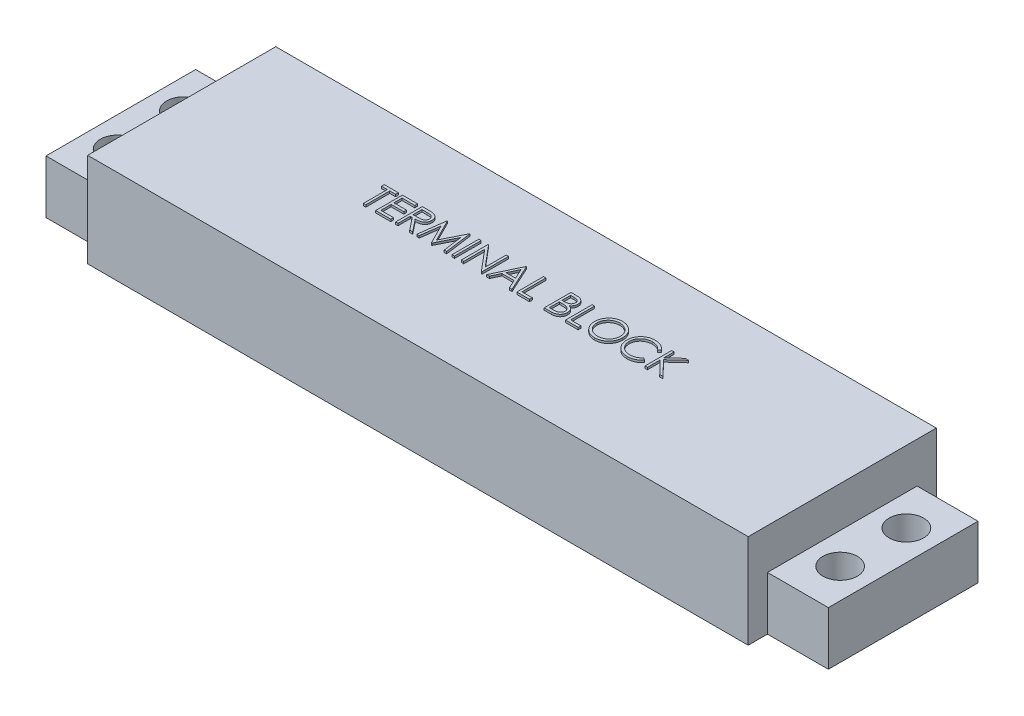
from build123d import *

# Parameters (mm, degrees)
SKETCH1_W           = 78.486
SKETCH1_H           = 22.352
BOSS_EXTRUDE1_DEPTH = 11.176
SKETCH1_4_W         = 7.239
SKETCH1_4_H         = 17.78
BOSS_EXTRUDE2_DEPTH = 6.35
SKETCH2_R           = 2.0499959
CUT_EXTRUDE1_DEPTH  = 49.226567367
SKETCH3_W           = 0.284935897
SKETCH3_H           = 3.175
BOSS_EXTRUDE3_DEPTH = 0.254


with BuildPart() as part:
    # Sketch1 → Boss-Extrude1 (new body)
    with BuildSketch(Plane(origin=(0, 0, 0), x_dir=(1, 0, 0), z_dir=(0, 1, 0))):
        Rectangle(SKETCH1_W, SKETCH1_H)
    extrude(amount=BOSS_EXTRUDE1_DEPTH)

    # Sketch1_4 → Boss-Extrude2 (add)
    with BuildSketch(Plane(origin=(0, 0, 0), x_dir=(1, 0, 0), z_dir=(0, 1, 0))):
        with Locations((-42.8625, 0)):
            Rectangle(SKETCH1_4_W, SKETCH1_4_H)
        with Locations((42.8625, 0)):
            Rectangle(SKETCH1_4_W, SKETCH1_4_H)
    extrude(amount=BOSS_EXTRUDE2_DEPTH)

    # Sketch2 → Cut-Extrude1 (cut, through all)
    with BuildSketch(Plane(origin=(0, 6.35, 0), x_dir=(1, 0, 0), z_dir=(0, 1, 0))):
        with Locations((-42.926, 3.937)):
            Circle(SKETCH2_R)
        with Locations((-42.926, -3.937)):
            Circle(SKETCH2_R)
        with Locations((42.926, -3.937)):
            Circle(SKETCH2_R)
        with Locations((42.926, 3.937)):
            Circle(SKETCH2_R)
    extrude(amount=-CUT_EXTRUDE1_DEPTH, mode=Mode.SUBTRACT)

    # Sketch3 → Boss-Extrude3 (add)
    # profile 1 of 13: a face of its own
    with BuildSketch(Plane(origin=(0, 11.176, 0), x_dir=(1, 0, 0), z_dir=(0, 1, 0))):
        Polygon((-18.35269826, 2.849358974), (-18.35269826, 3.175), (-16.683788004, 3.175), (-16.683788004, 2.849358974), (-17.375775183, 2.849358974), (-17.375775183, 0), (-17.660711081, 0), (-17.660711081, 2.849358974), align=None)
    # profile 2 of 13: a face of its own
    with BuildSketch(Plane(origin=(0, 11.176, 0), x_dir=(1, 0, 0), z_dir=(0, 1, 0))):
        Polygon((-16.195326465, 3.175), (-14.404300824, 3.175), (-14.404300824, 2.849358974), (-15.910390568, 2.849358974), (-15.910390568, 1.872435897), (-14.404300824, 1.872435897), (-14.404300824, 1.546794872), (-15.910390568, 1.546794872), (-15.910390568, 0.325641026), (-14.404300824, 0.325641026), (-14.404300824, 0), (-16.195326465, 0), align=None)
    # profile 3 of 13: a face of its own
    with BuildSketch(Plane(origin=(0, 11.176, 0), x_dir=(1, 0, 0), z_dir=(0, 1, 0))):
        with BuildLine():
            Line((-13.834429029, 3.175), (-13.199047419, 3.175))
            add(Edge.make_bspline(
                [(-13.199047419, 3.175), (-13.156646538, 3.174858861), (-13.07523215, 3.174587859), (-12.958597826, 3.173076774), (-12.852618959, 3.168745752), (-12.757350962, 3.16501868), (-12.672795582, 3.158222418), (-12.59869354, 3.151726689), (-12.535386129, 3.143223439), (-12.497063107, 3.135326377), (-12.479711481, 3.131750801)],
                knots=[0, 0, 0, 0, 1.410062039, 2.707475311, 3.878576406, 4.937260626, 5.877586885, 6.699081471, 7.410979367, 8, 8, 8, 8], degree=3))
            add(Edge.make_bspline(
                [(-12.479711481, 3.131750801), (-12.456482615, 3.126011521), (-12.410520417, 3.114655396), (-12.344344286, 3.090652758), (-12.281284864, 3.062876384), (-12.221604094, 3.030252152), (-12.165600912, 2.992537888), (-12.112697873, 2.950384662), (-12.062654917, 2.904023126), (-12.017495867, 2.852284377), (-11.974915442, 2.798004114), (-11.939002902, 2.739308563), (-11.90804531, 2.677929892), (-11.883397769, 2.613243877), (-11.863551322, 2.545877841), (-11.849557519, 2.475221576), (-11.84116537, 2.401596977), (-11.840310973, 2.351379445), (-11.839877747, 2.325916466)],
                knots=[0, 0, 0, 0, 1.027469482, 2.033020251, 3.019912614, 3.986113645, 4.951240523, 5.91722682, 6.890402269, 7.87763091, 8.8651537, 9.85103654, 10.82876324, 11.815024772, 12.821070561, 13.842952187, 14.906261191, 16, 16, 16, 16], degree=3))
            add(Edge.make_bspline(
                [(-11.839877747, 2.325916466), (-11.841210338, 2.283611764), (-11.843810569, 2.201064333), (-11.868054056, 2.081266248), (-11.907765613, 1.969515941), (-11.962487454, 1.86595412), (-12.032173692, 1.772599463), (-12.115925467, 1.690602407), (-12.2137895, 1.621986201), (-12.304893237, 1.574404013), (-12.38536969, 1.543930446), (-12.451621338, 1.522488892), (-12.523890667, 1.505922681), (-12.601485249, 1.491081704), (-12.684727994, 1.479876953), (-12.773419387, 1.471670399), (-12.867622682, 1.466541369), (-12.932337409, 1.465777551), (-12.965628949, 1.465384615)],
                knots=[0, 0, 0, 0, 1.260483769, 2.459530307, 3.627416485, 4.787058657, 5.939039949, 7.08810263, 8.267026773, 9.491475466, 10.141966685, 10.831826277, 11.566392101, 12.351337768, 13.187381173, 14.07005841, 15.007169909, 16, 16, 16, 16], degree=3))
            Line((-12.965628949, 1.465384615), (-11.799172619, 0))
            Line((-11.799172619, 0), (-12.151526385, 0))
            Line((-12.151526385, 0), (-13.317982715, 1.465384615))
            Line((-13.317982715, 1.465384615), (-13.549493132, 1.465384615))
            Line((-13.549493132, 1.465384615), (-13.549493132, 0))
            Line((-13.549493132, 0), (-13.834429029, 0))
            Line((-13.834429029, 0), (-13.834429029, 3.175))
        make_face()
        with BuildLine():
            Line((-13.549493132, 2.849358974), (-13.549493132, 1.791025641))
            Line((-13.549493132, 1.791025641), (-12.96817302, 1.786573518))
            add(Edge.make_bspline(
                [(-12.96817302, 1.786573518), (-12.94103127, 1.78656151), (-12.888422829, 1.786538236), (-12.81231294, 1.790161162), (-12.741446839, 1.7942826), (-12.676095585, 1.80058665), (-12.616229985, 1.808711086), (-12.56187996, 1.818873793), (-12.512956791, 1.830713879), (-12.455898831, 1.849039639), (-12.392184264, 1.87807367), (-12.322940725, 1.920315229), (-12.263974319, 1.973445788), (-12.214155972, 2.03420028), (-12.174124274, 2.100998877), (-12.145901196, 2.173040869), (-12.12799198, 2.248507533), (-12.125879657, 2.300376245), (-12.124813645, 2.326552484)],
                knots=[0, 0, 0, 0, 1.146690395, 2.22261258, 3.21895312, 4.145990853, 4.996080663, 5.770904154, 6.481378293, 7.121626537, 8.300444488, 9.431385265, 10.535395872, 11.636531494, 12.74115979, 13.810798291, 14.895190096, 16, 16, 16, 16], degree=3))
            add(Edge.make_bspline(
                [(-12.124813645, 2.326552484), (-12.12590414, 2.352085447), (-12.128065105, 2.402682464), (-12.145707916, 2.47675604), (-12.175543283, 2.546666773), (-12.215749885, 2.61213027), (-12.264734833, 2.67155333), (-12.322173134, 2.722396105), (-12.386494275, 2.764350976), (-12.44661172, 2.791161022), (-12.500345612, 2.807598317), (-12.546999661, 2.819165444), (-12.599715073, 2.828458641), (-12.658747811, 2.835904525), (-12.723845861, 2.842304367), (-12.795338381, 2.846614909), (-12.872751031, 2.849167486), (-12.926405747, 2.849293659), (-12.954180632, 2.849358974)],
                knots=[0, 0, 0, 0, 1.101028733, 2.181837193, 3.264309656, 4.369019818, 5.486613113, 6.575447106, 7.666700264, 8.788928104, 9.402425223, 10.0903467, 10.862060571, 11.710948788, 12.657782767, 13.684531032, 14.801375019, 16, 16, 16, 16], degree=3))
            Line((-12.954180632, 2.849358974), (-13.549493132, 2.849358974))
        make_face(mode=Mode.SUBTRACT)
    # profile 4 of 13: a face of its own
    with BuildSketch(Plane(origin=(0, 11.176, 0), x_dir=(1, 0, 0), z_dir=(0, 1, 0))):
        Polygon((-11.310711081, 0), (-10.891575464, 3.175), (-10.850870335, 3.175), (-9.540038004, 0.569871795), (-8.23238576, 3.175), (-8.191044614, 3.175), (-7.769364927, 0), (-8.055572859, 0), (-8.359589286, 2.284575321), (-9.505693052, 0), (-9.569930832, 0), (-10.720486722, 2.289663462), (-11.02386713, 0), align=None)
    # profile 5 of 13: a face of its own
    with BuildSketch(Plane(origin=(0, 11.176, 0), x_dir=(1, 0, 0), z_dir=(0, 1, 0))):
        with Locations((-6.975614927, 1.5875)):
            Rectangle(SKETCH3_W, SKETCH3_H)
    # profile 6 of 13: a face of its own
    with BuildSketch(Plane(origin=(0, 11.176, 0), x_dir=(1, 0, 0), z_dir=(0, 1, 0))):
        Polygon((-6.019044414, 0), (-6.019044414, 3.175), (-5.959258757, 3.175), (-3.861672619, 0.676086739), (-3.861672619, 3.175), (-3.576736722, 3.175), (-3.576736722, 0), (-3.64161052, 0), (-5.734108517, 2.493189103), (-5.734108517, 0), align=None)
    # profile 7 of 13: a face of its own
    with BuildSketch(Plane(origin=(0, 11.176, 0), x_dir=(1, 0, 0), z_dir=(0, 1, 0))):
        Polygon((-1.460070055, 3.175), (0.00531456, 0), (-0.304426025, 0), (-0.773807034, 1.017628205), (-2.213114927, 1.017628205), (-2.695852307, 0), (-3.006864927, 0), (-1.500775183, 3.175), align=None)
        Polygon((-1.483602707, 2.556154848), (-2.058562643, 1.343269231), (-0.923907194, 1.343269231), align=None, mode=Mode.SUBTRACT)
    # profile 8 of 13: a face of its own
    with BuildSketch(Plane(origin=(0, 11.176, 0), x_dir=(1, 0, 0), z_dir=(0, 1, 0))):
        Polygon((0.575186355, 3.175), (0.860122253, 3.175), (0.860122253, 0.325641026), (2.081276099, 0.325641026), (2.081276099, 0), (0.575186355, 0), align=None)
    # profile 9 of 13: a face of its own
    with BuildSketch(Plane(origin=(0, 11.176, 0), x_dir=(1, 0, 0), z_dir=(0, 1, 0))):
        with BuildLine():
            Line((3.831596612, 3.175), (4.451077782, 3.175))
            add(Edge.make_bspline(
                [(4.451077782, 3.175), (4.481402187, 3.174840569), (4.540178431, 3.174531553), (4.625648925, 3.169738998), (4.705703203, 3.163204241), (4.780364482, 3.152835514), (4.849598262, 3.140324401), (4.91361319, 3.125173468), (4.972205704, 3.107006469), (5.042157972, 3.078117342), (5.121914571, 3.035188468), (5.208273113, 2.97175327), (5.282118388, 2.894163107), (5.345787404, 2.806639555), (5.396406991, 2.710359248), (5.433027711, 2.607616984), (5.456212355, 2.499737975), (5.45859672, 2.425675949), (5.45980174, 2.388246194)],
                knots=[0, 0, 0, 0, 1.001505555, 1.941167018, 2.826882275, 3.653841531, 4.429895133, 5.150066043, 5.825578002, 6.45369114, 7.647487171, 8.808567382, 9.977351308, 11.170798116, 12.373658725, 13.556498008, 14.765093433, 16, 16, 16, 16], degree=3))
            add(Edge.make_bspline(
                [(5.45980174, 2.388246194), (5.458810035, 2.353182804), (5.45686124, 2.284279937), (5.438226023, 2.183501709), (5.409051702, 2.087570246), (5.368497655, 1.996835654), (5.315790844, 1.913348019), (5.253326512, 1.836433856), (5.177963984, 1.769349683), (5.121500473, 1.731845764), (5.092819568, 1.712795473)],
                knots=[0, 0, 0, 0, 1.044552857, 2.05264487, 3.044412934, 4.028983338, 5.005914585, 5.980388656, 6.974128949, 8, 8, 8, 8], degree=3))
            add(Edge.make_bspline(
                [(5.092819568, 1.712795473), (5.128887956, 1.698947938), (5.197895717, 1.672454174), (5.292860886, 1.625613431), (5.374680495, 1.574666374), (5.44398362, 1.519029624), (5.503254207, 1.459059489), (5.555009376, 1.393876635), (5.599170336, 1.322630762), (5.637009917, 1.246064698), (5.666536289, 1.164960259), (5.688648716, 1.080078197), (5.701319188, 0.991722887), (5.703122263, 0.931592578), (5.704032509, 0.901236979)],
                knots=[0, 0, 0, 0, 1.27268992, 2.434971085, 3.483601985, 4.442670788, 5.356604649, 6.2567628, 7.179492994, 8.113709626, 9.066344395, 10.018646069, 10.999752585, 12, 12, 12, 12], degree=3))
            add(Edge.make_bspline(
                [(5.704032509, 0.901236979), (5.70314637, 0.870242745), (5.701402867, 0.809260721), (5.688539607, 0.719675707), (5.666759917, 0.634064148), (5.636759663, 0.551872304), (5.597605278, 0.473259182), (5.54995491, 0.398135721), (5.493139134, 0.327256721), (5.429582103, 0.259834577), (5.357680014, 0.199212227), (5.280105008, 0.145222979), (5.195880132, 0.100821908), (5.10638868, 0.063523803), (5.010626765, 0.035032987), (4.9090244, 0.015100724), (4.801669212, 0.00167044), (4.728000366, 0.000566261), (4.69022041, 0)],
                knots=[0, 0, 0, 0, 0.978564426, 1.925352924, 2.850884081, 3.763762016, 4.682927383, 5.618979971, 6.567305752, 7.547517671, 8.540179244, 9.531824382, 10.526200242, 11.540722885, 12.589160233, 13.674978461, 14.80764778, 16, 16, 16, 16], degree=3))
            Line((4.69022041, 0), (3.831596612, 0))
            Line((3.831596612, 0), (3.831596612, 3.175))
        make_face()
        with BuildLine():
            Line((4.116532509, 2.849358974), (4.116532509, 1.831730769))
            Line((4.116532509, 1.831730769), (4.307973815, 1.831730769))
            add(Edge.make_bspline(
                [(4.307973815, 1.831730769), (4.33595808, 1.832093557), (4.390029381, 1.832794536), (4.468333859, 1.834802512), (4.541018697, 1.840425023), (4.607958431, 1.846045917), (4.669047648, 1.855185008), (4.724151008, 1.866063576), (4.774133307, 1.877568783), (4.831772752, 1.897135389), (4.897153212, 1.926052994), (4.966851814, 1.970931017), (5.028296654, 2.024383823), (5.080182674, 2.086061339), (5.122647365, 2.153975664), (5.15214195, 2.227043192), (5.172141986, 2.303442883), (5.17394859, 2.355892298), (5.174865842, 2.382522035)],
                knots=[0, 0, 0, 0, 1.156816544, 2.235205308, 3.236616184, 4.169592532, 5.011045266, 5.787822928, 6.49130361, 7.128639758, 8.301311294, 9.436451833, 10.541879658, 11.654887649, 12.756523258, 13.837046038, 14.901820046, 16, 16, 16, 16], degree=3))
            add(Edge.make_bspline(
                [(5.174865842, 2.382522035), (5.174388522, 2.400143985), (5.173452205, 2.434711364), (5.165783852, 2.485102564), (5.15275041, 2.532495111), (5.13600973, 2.577538482), (5.112615705, 2.618824232), (5.085071706, 2.657779845), (5.051792544, 2.693078696), (5.013912696, 2.726071026), (4.970362017, 2.755321419), (4.921166488, 2.780939826), (4.865660524, 2.801568959), (4.804779577, 2.819635755), (4.737586519, 2.832325136), (4.664856745, 2.842896423), (4.585994536, 2.848278267), (4.531434336, 2.848990704), (4.503231227, 2.849358974)],
                knots=[0, 0, 0, 0, 0.91205012, 1.789085906, 2.630437955, 3.453916878, 4.269457761, 5.079663411, 5.91843418, 6.774407191, 7.675494373, 8.627863946, 9.638891023, 10.736472738, 11.911756761, 13.175263542, 14.539845004, 16, 16, 16, 16], degree=3))
            Line((4.503231227, 2.849358974), (4.116532509, 2.849358974))
        make_face(mode=Mode.SUBTRACT)
        with BuildLine():
            Line((4.116532509, 1.506089744), (4.116532509, 0.325641026))
            Line((4.116532509, 0.325641026), (4.522311756, 0.325641026))
            add(Edge.make_bspline(
                [(4.522311756, 0.325641026), (4.551357496, 0.325989139), (4.60733933, 0.326660083), (4.688166875, 0.328850429), (4.763081548, 0.333832707), (4.831741499, 0.341675728), (4.894888124, 0.350183321), (4.951763898, 0.361623555), (5.002829866, 0.374730826), (5.062042988, 0.394991111), (5.128721171, 0.426465766), (5.200576733, 0.473922243), (5.264463374, 0.530458387), (5.318715288, 0.59589143), (5.36317707, 0.667039848), (5.395521661, 0.742464559), (5.41547051, 0.820919287), (5.417885478, 0.874410519), (5.419096612, 0.901236979)],
                knots=[0, 0, 0, 0, 1.160039823, 2.235823828, 3.228722157, 4.157150951, 4.99529583, 5.772374946, 6.472645482, 7.099169577, 8.269452708, 9.405989375, 10.527446681, 11.663510218, 12.788923519, 13.866172445, 14.929861265, 16, 16, 16, 16], degree=3))
            add(Edge.make_bspline(
                [(5.419096612, 0.901236979), (5.418846146, 0.918013081), (5.418349254, 0.951294684), (5.410855696, 1.000204035), (5.3999574, 1.047580363), (5.38586817, 1.093552313), (5.365349082, 1.137288733), (5.341394574, 1.179654626), (5.313308159, 1.220705997), (5.269543809, 1.272605684), (5.205887794, 1.332401831), (5.115439505, 1.390946565), (5.012594635, 1.438161362), (4.938002552, 1.458208744), (4.899470209, 1.468564704)],
                knots=[0, 0, 0, 0, 0.723448775, 1.435228256, 2.130040452, 2.821711965, 3.505591119, 4.210454504, 4.921174351, 5.648778258, 7.137944449, 8.670945889, 10.280296675, 12, 12, 12, 12], degree=3))
            add(Edge.make_bspline(
                [(4.899470209, 1.468564704), (4.884022387, 1.471698958), (4.850528321, 1.478494669), (4.795911444, 1.485668086), (4.733558192, 1.492058961), (4.663324582, 1.496786226), (4.585121754, 1.50167259), (4.498782693, 1.503572892), (4.404659986, 1.505840078), (4.339352619, 1.506004393), (4.305429745, 1.506089744)],
                knots=[0, 0, 0, 0, 0.634451884, 1.375622551, 2.216452059, 3.157844607, 4.20941857, 5.370758133, 6.634282058, 8, 8, 8, 8], degree=3))
            Line((4.305429745, 1.506089744), (4.116532509, 1.506089744))
        make_face(mode=Mode.SUBTRACT)
    # profile 10 of 13: a face of its own
    with BuildSketch(Plane(origin=(0, 11.176, 0), x_dir=(1, 0, 0), z_dir=(0, 1, 0))):
        Polygon((6.35531456, 3.175), (6.640250458, 3.175), (6.640250458, 0.325641026), (7.861404304, 0.325641026), (7.861404304, 0), (6.35531456, 0), align=None)
    # profile 11 of 13: a face of its own
    with BuildSketch(Plane(origin=(0, 11.176, 0), x_dir=(1, 0, 0), z_dir=(0, 1, 0))):
        with BuildLine():
            add(Edge.make_bspline(
                [(9.87630815, 3.256410256), (9.935098361, 3.2549212), (10.050567184, 3.251996571), (10.220270841, 3.229609098), (10.382282106, 3.19087828), (10.537920732, 3.139295432), (10.685325075, 3.070484668), (10.825604642, 2.98731314), (10.958425663, 2.888909496), (11.081997917, 2.776034411), (11.195079579, 2.653222278), (11.294707347, 2.522160174), (11.378202856, 2.383640546), (11.446769963, 2.23807965), (11.500562273, 2.085806679), (11.537681692, 1.926009834), (11.561392728, 1.759724479), (11.564164754, 1.646307252), (11.565570971, 1.588772035)],
                knots=[0, 0, 0, 0, 1.065120563, 2.091984664, 3.0946048, 4.079830382, 5.057816894, 6.036188127, 7.030412546, 8.04752943, 9.064399622, 10.05169764, 11.02544977, 11.989514704, 12.962713494, 13.945757189, 14.957906945, 16, 16, 16, 16], degree=3))
            add(Edge.make_bspline(
                [(11.565570971, 1.588772035), (11.56416496, 1.531660637), (11.561393551, 1.419087456), (11.537654732, 1.253857332), (11.500424682, 1.095025057), (11.447269498, 0.942855786), (11.379029242, 0.797188996), (11.294977765, 0.658407974), (11.195971096, 0.526467222), (11.083297738, 0.402812161), (10.96046965, 0.289421599), (10.828725051, 0.190616618), (10.691026825, 0.105595448), (10.545603018, 0.037755973), (10.39438227, -0.016465698), (10.236011163, -0.053434155), (10.071231789, -0.077280259), (9.958863093, -0.080018484), (9.901748855, -0.081410256)],
                knots=[0, 0, 0, 0, 1.043624062, 2.057103931, 3.04512605, 4.022047818, 4.998200453, 5.980619268, 6.982898556, 8.009068085, 9.034988726, 10.034168286, 11.015286542, 11.987931943, 12.962482838, 13.94673481, 14.956375938, 16, 16, 16, 16], degree=3))
            add(Edge.make_bspline(
                [(9.901748855, -0.081410256), (9.844213937, -0.080004741), (9.730797299, -0.077234097), (9.564302988, -0.053483822), (9.404393892, -0.016344211), (9.251527302, 0.036732206), (9.105617973, 0.105327837), (8.966380541, 0.188970381), (8.834373886, 0.288218287), (8.710692444, 0.400855109), (8.5975271, 0.523475017), (8.498866809, 0.654860377), (8.415205456, 0.792433541), (8.346840148, 0.936576295), (8.29271596, 1.086591818), (8.255790875, 1.243480794), (8.231900404, 1.406348774), (8.229147364, 1.517240546), (8.227750458, 1.573507612)],
                knots=[0, 0, 0, 0, 1.053102029, 2.075944431, 3.073151272, 4.055350789, 5.033113405, 6.020478099, 7.024410459, 8.052272461, 9.079885166, 10.07527673, 11.055994387, 12.023226415, 12.992069828, 13.970394897, 14.97016774, 16, 16, 16, 16], degree=3))
            add(Edge.make_bspline(
                [(8.227750458, 1.573507612), (8.228235449, 1.611274391), (8.229199312, 1.686331503), (8.240803204, 1.797789061), (8.257641319, 1.907454158), (8.281773054, 2.015014947), (8.313334066, 2.120208126), (8.35057412, 2.223759175), (8.396058122, 2.324618696), (8.447475567, 2.423264487), (8.504863064, 2.518158801), (8.568250351, 2.607856709), (8.635411007, 2.693110899), (8.7090378, 2.771712109), (8.786704147, 2.845946926), (8.869669961, 2.914674534), (8.957428997, 2.978514668), (9.05035887, 3.036045977), (9.146169734, 3.088078906), (9.244936525, 3.132730157), (9.345317843, 3.17105337), (9.447783845, 3.20211469), (9.552062432, 3.226636608), (9.658381193, 3.243334708), (9.76665543, 3.254968196), (9.839599984, 3.255927501), (9.87630815, 3.256410256)],
                knots=[0, 0, 0, 0, 1.037015668, 2.060948919, 3.074880161, 4.083647147, 5.086022904, 6.090072063, 7.104153813, 8.122640571, 9.144368836, 10.147691507, 11.138137339, 12.123020368, 13.103399296, 14.087645067, 15.080126199, 16.082011238, 17.087798457, 18.072939717, 19.057185487, 20.037253025, 21.01195951, 21.997135196, 22.992090687, 24, 24, 24, 24], degree=3))
        make_face()
        with BuildLine():
            add(Edge.make_bspline(
                [(9.890300538, 2.930769231), (9.86017012, 2.930401937), (9.800197334, 2.929670862), (9.711039219, 2.920040892), (9.623053679, 2.906315921), (9.536222543, 2.886738399), (9.450909124, 2.860064722), (9.366318196, 2.829366184), (9.28322114, 2.791972766), (9.201892284, 2.74972467), (9.123047894, 2.702962435), (9.048650658, 2.651280903), (8.978507974, 2.595892072), (8.912791582, 2.536666676), (8.851694447, 2.473303109), (8.794014039, 2.406761971), (8.742062347, 2.335141327), (8.694450431, 2.260383315), (8.65184389, 2.182585309), (8.613956747, 2.102566362), (8.582965111, 2.019673747), (8.557689955, 1.934806761), (8.536735126, 1.848099815), (8.523460067, 1.758895152), (8.513724284, 1.667641015), (8.513034995, 1.605971762), (8.512686355, 1.574779647)],
                knots=[0, 0, 0, 0, 1.008559885, 2.007477868, 2.99961109, 3.989939068, 4.984837346, 5.991145699, 7.001802488, 8.033829008, 9.059044045, 10.069351652, 11.065060232, 12.050310815, 13.029377138, 14.011219647, 14.996725999, 15.989392538, 16.977580475, 17.965360261, 18.951710183, 19.937753436, 20.929683414, 21.935841486, 22.955955122, 24, 24, 24, 24], degree=3))
            add(Edge.make_bspline(
                [(8.512686355, 1.574779647), (8.513842837, 1.52891249), (8.516117995, 1.438677602), (8.536036648, 1.306445071), (8.56671801, 1.179364983), (8.611945764, 1.05813268), (8.668506679, 0.94170608), (8.738381072, 0.831118014), (8.8211661, 0.726338592), (8.915203728, 0.628099312), (9.018003611, 0.538432047), (9.127162588, 0.459725241), (9.241511217, 0.393131657), (9.361347694, 0.338879913), (9.486032247, 0.29589065), (9.616368312, 0.266427892), (9.751487657, 0.247037301), (9.843590466, 0.245175158), (9.890300538, 0.244230769)],
                knots=[0, 0, 0, 0, 1.032063989, 2.030389145, 3.003944642, 3.970395727, 4.937377036, 5.913328081, 6.909231446, 7.93887556, 8.970685674, 9.976071282, 10.964166581, 11.944589148, 12.933237628, 13.927779006, 14.949070134, 16, 16, 16, 16], degree=3))
            add(Edge.make_bspline(
                [(9.890300538, 0.244230769), (9.9216963, 0.24466212), (9.983963526, 0.245517617), (10.07657875, 0.254134274), (10.167525456, 0.267951755), (10.256676082, 0.287845993), (10.343929446, 0.31274453), (10.429649732, 0.342324398), (10.512923895, 0.379228061), (10.594802462, 0.420002274), (10.673176196, 0.466484417), (10.747993286, 0.516411882), (10.817367925, 0.57171913), (10.883035154, 0.630064575), (10.944383129, 0.692624637), (11.000996993, 0.759317981), (11.052686113, 0.830565577), (11.10027995, 0.905210195), (11.142737195, 0.983221081), (11.179729663, 1.063530146), (11.211113283, 1.145939638), (11.236448426, 1.230568421), (11.256301667, 1.317255762), (11.269981308, 1.406117733), (11.279550249, 1.496976565), (11.280271498, 1.558429921), (11.280635073, 1.589408053)],
                knots=[0, 0, 0, 0, 1.047197238, 2.076906641, 3.100256066, 4.114471768, 5.12198147, 6.126382909, 7.136867548, 8.15857795, 9.17633901, 10.174870724, 11.156907918, 12.133735059, 13.104061851, 14.077631395, 15.04955518, 16.038496417, 17.029181396, 18.010275684, 18.986308667, 19.968651475, 20.955262928, 21.950658345, 22.966943676, 24, 24, 24, 24], degree=3))
            add(Edge.make_bspline(
                [(11.280635073, 1.589408053), (11.280271206, 1.62017426), (11.27954941, 1.6812047), (11.269985879, 1.771429871), (11.256287214, 1.859652427), (11.236545329, 1.94552602), (11.211099833, 2.029072539), (11.179724183, 2.110213517), (11.14272609, 2.189251237), (11.100264343, 2.265990349), (11.052534275, 2.339627433), (11.000378783, 2.410023907), (10.94289736, 2.475857751), (10.881732323, 2.538754224), (10.815355877, 2.597371881), (10.744068696, 2.651730167), (10.668736217, 2.703140923), (10.588973653, 2.749519112), (10.506655924, 2.792349166), (10.422188262, 2.829044004), (10.336527579, 2.860224427), (10.249891705, 2.886819102), (10.161551432, 2.906239244), (10.072103673, 2.92005326), (9.981672181, 2.92966751), (9.920854404, 2.930400825), (9.890300538, 2.930769231)],
                knots=[0, 0, 0, 0, 1.02996197, 2.043119294, 3.035359645, 4.018872909, 4.991431989, 5.957985074, 6.929999688, 7.912076566, 8.892894881, 9.867085534, 10.843653904, 11.817741046, 12.803660682, 13.806313499, 14.818574707, 15.856120519, 16.894564902, 17.924820532, 18.937903209, 19.946497019, 20.957711757, 21.963978472, 22.977135795, 24, 24, 24, 24], degree=3))
        make_face(mode=Mode.SUBTRACT)
    # profile 12 of 13: a face of its own
    with BuildSketch(Plane(origin=(0, 11.176, 0), x_dir=(1, 0, 0), z_dir=(0, 1, 0))):
        with BuildLine():
            Line((15.147622253, 2.592407853), (14.898303342, 2.401602564))
            add(Edge.make_bspline(
                [(14.898303342, 2.401602564), (14.880518001, 2.422798837), (14.845187103, 2.46490561), (14.788346255, 2.524032768), (14.729108336, 2.579427684), (14.66749599, 2.631354246), (14.602400217, 2.677996598), (14.535397921, 2.721785384), (14.465368266, 2.761035404), (14.368529193, 2.808626827), (14.241848645, 2.85828941), (14.082377612, 2.899930199), (13.91590683, 2.92643798), (13.802334722, 2.929308943), (13.744567365, 2.930769231)],
                knots=[0, 0, 0, 0, 0.757959112, 1.505699292, 2.245454638, 2.979532153, 3.711538275, 4.438200793, 5.171680507, 5.909471876, 7.393775596, 8.890124382, 10.418191784, 12, 12, 12, 12], degree=3))
            add(Edge.make_bspline(
                [(13.744567365, 2.930769231), (13.7127418, 2.930402779), (13.649386043, 2.929673277), (13.555362071, 2.920049285), (13.463093803, 2.906522687), (13.372641258, 2.886451858), (13.284119575, 2.861076696), (13.196950038, 2.830755071), (13.112394709, 2.793240323), (13.029283878, 2.751776402), (12.949655594, 2.704942934), (12.874312801, 2.653858679), (12.803530287, 2.599095284), (12.73725206, 2.540447495), (12.675410364, 2.478179431), (12.618453304, 2.411627492), (12.566577967, 2.341004449), (12.518756094, 2.267241573), (12.475927401, 2.190553719), (12.440068153, 2.110657048), (12.408313506, 2.028919754), (12.383186336, 1.944418344), (12.363297667, 1.857747406), (12.349574716, 1.768674334), (12.340060174, 1.677385211), (12.339334299, 1.61550962), (12.338968407, 1.584319912)],
                knots=[0, 0, 0, 0, 1.054917814, 2.100044995, 3.131103042, 4.146048494, 5.169673617, 6.183595914, 7.203665975, 8.234915748, 9.262203917, 10.264457458, 11.251630812, 12.227803204, 13.197192746, 14.159520551, 15.12972552, 16.100847026, 17.073214652, 18.039054194, 19.002613845, 19.979014051, 20.95965708, 21.949030935, 22.966165397, 24, 24, 24, 24], degree=3))
            add(Edge.make_bspline(
                [(12.338968407, 1.584319912), (12.340113057, 1.537392215), (12.342360425, 1.445255905), (12.362361414, 1.310299709), (12.392755318, 1.181013097), (12.43830802, 1.058204241), (12.494477445, 0.940358801), (12.565452857, 0.829470699), (12.647655001, 0.723864244), (12.742246796, 0.626035284), (12.846029215, 0.536669262), (12.957379106, 0.457974091), (13.076019139, 0.392374162), (13.200639367, 0.337785982), (13.332198771, 0.295824522), (13.47046077, 0.26628421), (13.615124651, 0.247014518), (13.713975464, 0.245169672), (13.764283911, 0.244230769)],
                knots=[0, 0, 0, 0, 1.029171465, 2.020641659, 2.987623507, 3.938342917, 4.889210282, 5.84687017, 6.821220943, 7.821438502, 8.827599549, 9.822697543, 10.807740252, 11.797342354, 12.80366471, 13.83203677, 14.896651826, 16, 16, 16, 16], degree=3))
            add(Edge.make_bspline(
                [(13.764283911, 0.244230769), (13.819712779, 0.245762734), (13.928810051, 0.248778006), (14.088801046, 0.274322468), (14.241959205, 0.315740722), (14.388292766, 0.373705266), (14.527389195, 0.449057348), (14.659466165, 0.540404709), (14.784635161, 0.648616268), (14.859901967, 0.731241677), (14.898303342, 0.773397436)],
                knots=[0, 0, 0, 0, 1.028121516, 2.023589091, 2.998037872, 3.967518031, 4.937445131, 5.927275754, 6.942489185, 8, 8, 8, 8], degree=3))
            Line((14.898303342, 0.773397436), (15.147622253, 0.5845002))
            add(Edge.make_bspline(
                [(15.147622253, 0.5845002), (15.127557967, 0.558611748), (15.087525503, 0.506958846), (15.022702874, 0.434140938), (14.954415611, 0.365647992), (14.882156503, 0.302032221), (14.806756792, 0.24202067), (14.726862623, 0.187318294), (14.643524286, 0.137161564), (14.557024152, 0.091235711), (14.467454124, 0.050489351), (14.37492153, 0.01560629), (14.279825222, -0.014442717), (14.182160854, -0.039164117), (14.081725846, -0.058460028), (13.97888263, -0.071359305), (13.873409243, -0.080196613), (13.802251668, -0.081002079), (13.766191964, -0.081410256)],
                knots=[0, 0, 0, 0, 0.986787822, 1.968848986, 2.935600012, 3.899624008, 4.868462664, 5.837806735, 6.815139263, 7.798259679, 8.787526145, 9.778297419, 10.776456485, 11.791383307, 12.812564526, 13.85620153, 14.913611965, 16, 16, 16, 16], degree=3))
            add(Edge.make_bspline(
                [(13.766191964, -0.081410256), (13.732043781, -0.081172592), (13.664519976, -0.080702639), (13.564826108, -0.073089745), (13.467771274, -0.062703197), (13.373632864, -0.047063936), (13.281897158, -0.028608713), (13.193395771, -0.003869787), (13.10725783, 0.023842671), (13.023829406, 0.056413623), (12.943039536, 0.093167589), (12.865148793, 0.134707074), (12.790193, 0.180682766), (12.717435226, 0.23008124), (12.647950275, 0.284489221), (12.581136005, 0.343151096), (12.516617759, 0.405869149), (12.476701038, 0.451094623), (12.456631668, 0.473833133)],
                knots=[0, 0, 0, 0, 1.114604814, 2.203992996, 3.262667896, 4.300477797, 5.318619304, 6.316056647, 7.298880507, 8.271930387, 9.238335007, 10.195173496, 11.151986948, 12.108099108, 13.064862484, 14.031167946, 15.010108607, 16, 16, 16, 16], degree=3))
            add(Edge.make_bspline(
                [(12.456631668, 0.473833133), (12.424486477, 0.513331212), (12.36058418, 0.591850513), (12.27882731, 0.719109939), (12.208843456, 0.851977528), (12.152259585, 0.991151321), (12.10802482, 1.136319022), (12.07738045, 1.28755381), (12.057467209, 1.444714444), (12.055190019, 1.551609245), (12.054032509, 1.605944511)],
                knots=[0, 0, 0, 0, 0.994628077, 1.977248131, 2.950237994, 3.925870899, 4.908910175, 5.911660606, 6.938484602, 8, 8, 8, 8], degree=3))
            add(Edge.make_bspline(
                [(12.054032509, 1.605944511), (12.055443292, 1.663054101), (12.058218919, 1.775413654), (12.081800819, 1.940308598), (12.119736441, 2.098288795), (12.173617904, 2.249059335), (12.241930616, 2.393413232), (12.326319044, 2.530247753), (12.425802809, 2.660437993), (12.539601674, 2.782008518), (12.6643949, 2.893169216), (12.798034109, 2.990964844), (12.940257733, 3.072351447), (13.089498927, 3.14038368), (13.246875224, 3.192675443), (13.412050851, 3.229281549), (13.584715438, 3.252066361), (13.70251921, 3.254946728), (13.762375858, 3.256410256)],
                knots=[0, 0, 0, 0, 1.032925535, 2.032216505, 3.007276963, 3.968222605, 4.92396291, 5.891752235, 6.871517503, 7.883894988, 8.900124299, 9.891468569, 10.874487609, 11.85992873, 12.854644235, 13.869047385, 14.917252991, 16, 16, 16, 16], degree=3))
            add(Edge.make_bspline(
                [(13.762375858, 3.256410256), (13.798856129, 3.255972888), (13.871065152, 3.255107162), (13.97788363, 3.246665162), (14.081880598, 3.232592104), (14.183127703, 3.213436813), (14.282117505, 3.189663028), (14.378093437, 3.1586929), (14.471618675, 3.12328119), (14.56210337, 3.082497439), (14.649113383, 3.036716895), (14.732621615, 2.986447007), (14.811964737, 2.931750098), (14.887701049, 2.87309136), (14.958563612, 2.80922981), (15.026564382, 2.741921991), (15.089394075, 2.669229165), (15.12817733, 2.618061832), (15.147622253, 2.592407853)],
                knots=[0, 0, 0, 0, 1.096760587, 2.17092713, 3.219439832, 4.250915756, 5.268269357, 6.278326846, 7.281116186, 8.274029601, 9.260640565, 10.235837813, 11.203064059, 12.156899882, 13.114053108, 14.069676657, 15.032185724, 16, 16, 16, 16], degree=3))
        make_face()
    # profile 13 of 13: a face of its own
    with BuildSketch(Plane(origin=(0, 11.176, 0), x_dir=(1, 0, 0), z_dir=(0, 1, 0))):
        Polygon((15.798904304, 3.175), (16.083840201, 3.175), (16.083840201, 1.965930489), (17.407392886, 3.175), (17.81380815, 3.175), (16.253656908, 1.750320513), (17.935923535, 0), (17.556221011, 0), (16.083840201, 1.532166466), (16.083840201, 0), (15.798904304, 0), align=None)
    extrude(amount=BOSS_EXTRUDE3_DEPTH)


solid = part.part
